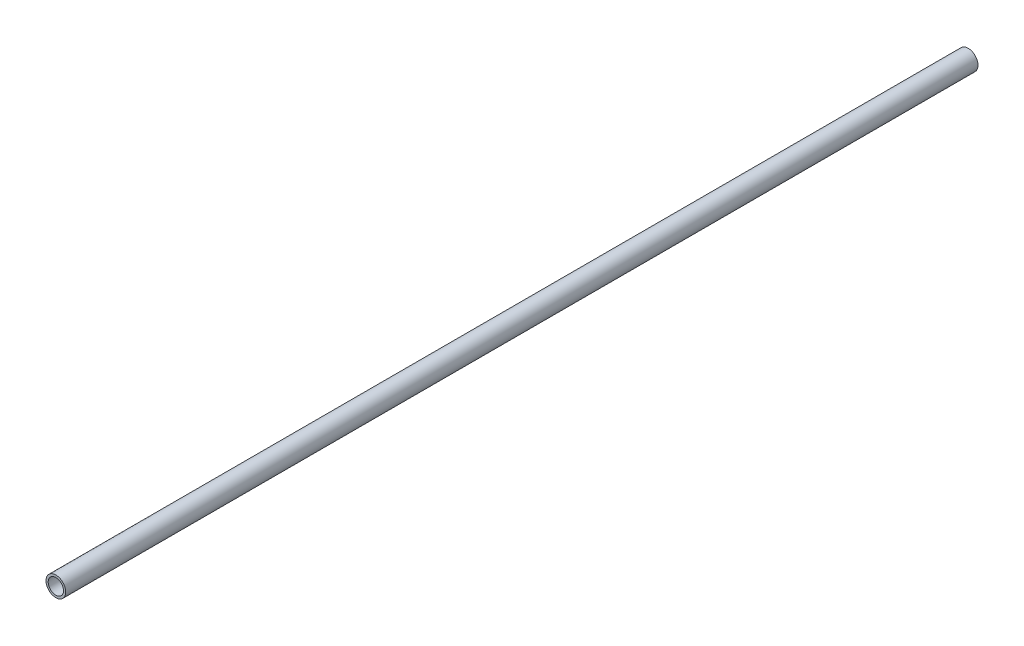
from build123d import *

# Parameters (mm, degrees)
SKETCH1_R           = 13.716
BOSS_EXTRUDE1_DEPTH = 1270
SKETCH2_R           = 10.668
CUT_EXTRUDE1_DEPTH  = 1271


with BuildPart() as part:
    # Sketch1 → Boss-Extrude1 (new body)
    with BuildSketch(Plane.XY):
        with Locations((-7.319167791, 4.997022186)):
            Circle(SKETCH1_R)
    extrude(amount=BOSS_EXTRUDE1_DEPTH)

    # Sketch2 → Cut-Extrude1 (cut, through all)
    with BuildSketch(Plane(origin=(0, 0, 0), x_dir=(-1, 0, 0), z_dir=(0, 0, -1))):
        with Locations((7.319167791, 4.997022186)):
            Circle(SKETCH2_R)
    extrude(amount=-CUT_EXTRUDE1_DEPTH, mode=Mode.SUBTRACT)


solid = part.part
